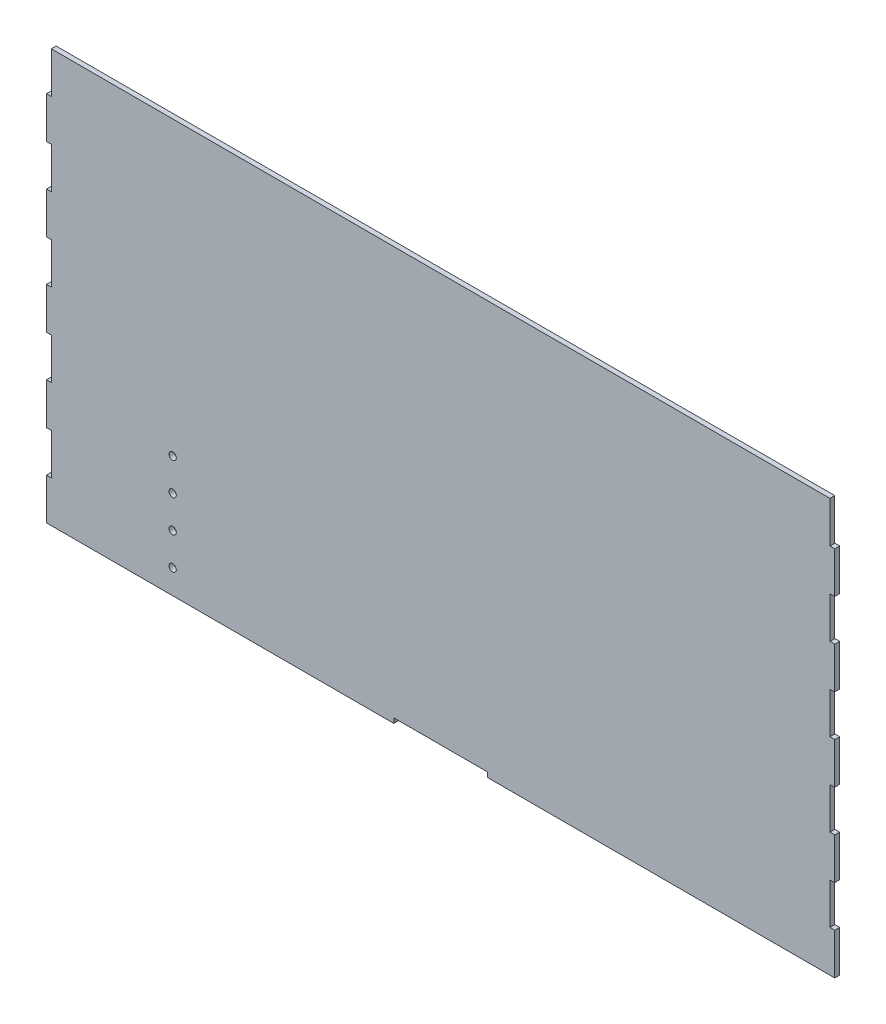
from build123d import *

# Parameters (mm, degrees)
SKETCH1_W           = 977.375
SKETCH1_H           = 512
BOSS_EXTRUDE1_DEPTH = 6
CUT_EXTRUDE3_DEPTH  = 10
LPATTERN1_COUNT     = 5
LPATTERN1_PITCH     = 102.4
SKETCH8_W           = 6
SKETCH8_H           = 0.580661117
CUT_EXTRUDE4_DEPTH  = 10
CUT_EXTRUDE5_DEPTH  = 10
LPATTERN4_COUNT     = 5
LPATTERN4_PITCH     = 102.4
SKETCH11_W          = 6
SKETCH11_H          = 0.733192148
CUT_EXTRUDE6_DEPTH  = 10
SKETCH14_W          = 116
SKETCH14_H          = 6
CUT_EXTRUDE9_DEPTH  = 10
SKETCH15_R          = 4.5
CUT_EXTRUDE11_DEPTH = 10
LPATTERN5_COUNT     = 4
LPATTERN5_PITCH     = 40


with BuildPart() as part:
    # Sketch1 → Boss-Extrude1 (new body)
    with BuildSketch(Plane.XY):
        Rectangle(SKETCH1_W, SKETCH1_H)
    extrude(amount=BOSS_EXTRUDE1_DEPTH)

    # Sketch7 → Cut-Extrude3 (cut)
    with BuildSketch(Plane.XY.offset(6)):
        with BuildLine():
            add(Edge.make_bspline(
                [(488.6875, -204.8), (488.6875, -204.6), (485.6875, -204.6), (482.6875, -204.6), (482.6875, -204.8)],
                knots=[0, 0, 0, 1.570796327, 1.570796327, 3.141592654, 3.141592654, 3.141592654], degree=2, weights=[1, 0.707106781, 1, 0.707106781, 1]))
            Line((488.6875, -204.8), (488.6875, -153.6))
            add(Edge.make_bspline(
                [(482.6875, -153.6), (482.6875, -153.8), (485.6875, -153.8), (488.6875, -153.8), (488.6875, -153.6)],
                knots=[3.141592654, 3.141592654, 3.141592654, 4.71238898, 4.71238898, 6.283185307, 6.283185307, 6.283185307], degree=2, weights=[1, 0.707106781, 1, 0.707106781, 1]))
            Line((482.6875, -153.6), (482.6875, -204.8))
        make_face()
    cut_extrude3 = extrude(amount=-CUT_EXTRUDE3_DEPTH, mode=Mode.SUBTRACT)

    # LPattern1: Cut-Extrude3 ×5
    with Locations(*[(0, i * LPATTERN1_PITCH, 0) for i in range(1, LPATTERN1_COUNT)]):
        add(cut_extrude3, mode=Mode.SUBTRACT)

    # Sketch8 → Cut-Extrude4 (cut)
    with BuildSketch(Plane.XY.offset(6)):
        with Locations((485.6875, 255.709669442)):
            Rectangle(SKETCH8_W, SKETCH8_H)
    extrude(amount=-CUT_EXTRUDE4_DEPTH, mode=Mode.SUBTRACT)

    # Sketch10 → Cut-Extrude5 (cut)
    with BuildSketch(Plane.XY.offset(6)):
        with BuildLine():
            Line((-488.6875, -153.6), (-488.6875, -204.8))
            add(Edge.make_bspline(
                [(-482.6875, -204.8), (-482.6875, -204.6), (-485.6875, -204.6), (-488.6875, -204.6), (-488.6875, -204.8)],
                knots=[0, 0, 0, 1.570796327, 1.570796327, 3.141592654, 3.141592654, 3.141592654], degree=2, weights=[1, 0.707106781, 1, 0.707106781, 1]))
            Line((-482.6875, -204.8), (-482.6875, -153.6))
            add(Edge.make_bspline(
                [(-488.6875, -153.6), (-488.6875, -153.8), (-485.6875, -153.8), (-482.6875, -153.8), (-482.6875, -153.6)],
                knots=[3.141592654, 3.141592654, 3.141592654, 4.71238898, 4.71238898, 6.283185307, 6.283185307, 6.283185307], degree=2, weights=[1, 0.707106781, 1, 0.707106781, 1]))
        make_face()
    cut_extrude5 = extrude(amount=-CUT_EXTRUDE5_DEPTH, mode=Mode.SUBTRACT)

    # LPattern4: Cut-Extrude5 ×5
    with Locations(*[(0, i * LPATTERN4_PITCH, 0) for i in range(1, LPATTERN4_COUNT)]):
        add(cut_extrude5, mode=Mode.SUBTRACT)

    # Sketch11 → Cut-Extrude6 (cut)
    with BuildSketch(Plane.XY.offset(6)):
        with Locations((-485.6875, 255.633403926)):
            Rectangle(SKETCH11_W, SKETCH11_H)
    extrude(amount=-CUT_EXTRUDE6_DEPTH, mode=Mode.SUBTRACT)

    # Sketch14 → Cut-Extrude9 (cut)
    with BuildSketch(Plane.XY.offset(6)):
        with Locations((0, -253.030374654)):
            Rectangle(SKETCH14_W, SKETCH14_H)
    extrude(amount=-CUT_EXTRUDE9_DEPTH, mode=Mode.SUBTRACT)

    # Sketch15 → Cut-Extrude11 (cut)
    with BuildSketch(Plane.XY.offset(6)):
        with Locations((-332.1875, -226)):
            Circle(SKETCH15_R)
    cut_extrude11 = extrude(amount=-CUT_EXTRUDE11_DEPTH, mode=Mode.SUBTRACT)

    # LPattern5: Cut-Extrude11 ×4
    with Locations(*[(0, i * LPATTERN5_PITCH, 0) for i in range(1, LPATTERN5_COUNT)]):
        add(cut_extrude11, mode=Mode.SUBTRACT)


solid = part.part
